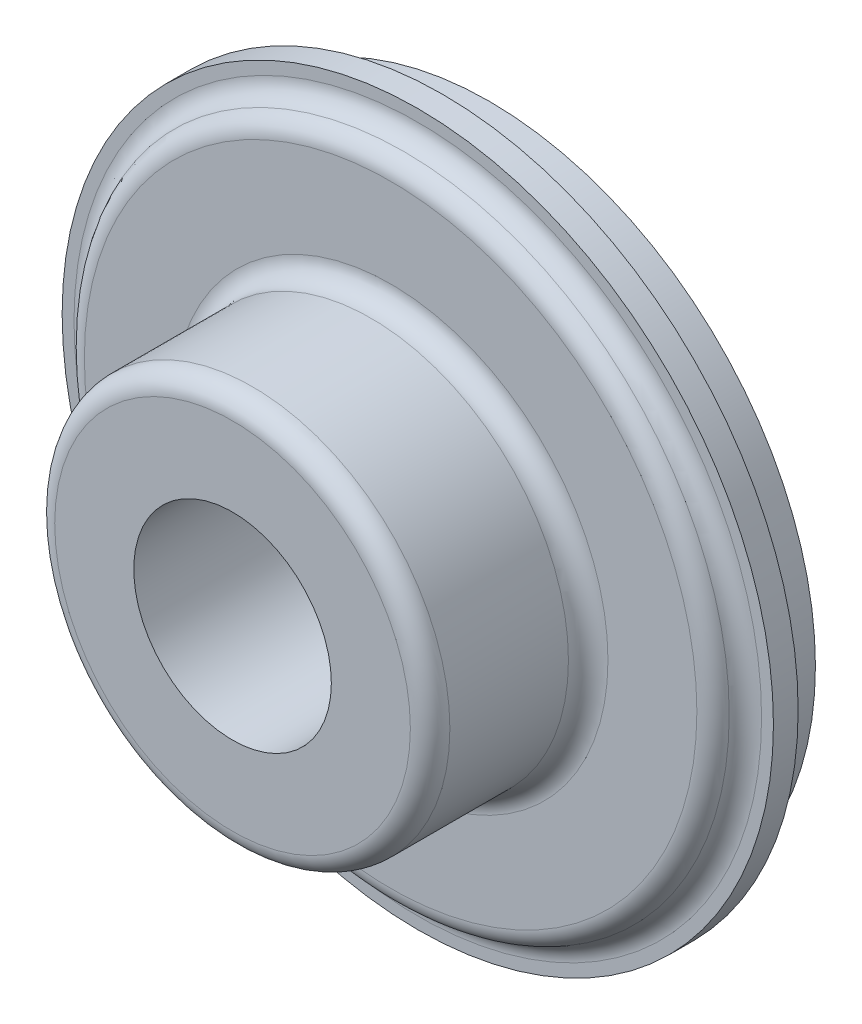
from build123d import *


with BuildPart() as part:
    # Sketch1 → Revolve1 (revolve)
    with BuildSketch(Plane(origin=(0, 0, 0), x_dir=(1, 0, 0), z_dir=(0, 1, 0))):
        with BuildLine():
            Line((22, -227), (31, -227))
            ThreePointArc((31, -227), (32.17260394, -226.620185175), (32.899835519, -225.625))
            ThreePointArc((32.899835519, -225.625), (33.627067098, -224.629814825), (34.799671038, -224.25))
            Line((34.799671038, -224.25), (36, -224.25))
            Line((36, -224.25), (36, -221.75))
            Line((36, -221.75), (33, -221.75))
            Line((33, -221.75), (33, -217))
            Line((33, -217), (27, -217))
            Line((27, -217), (27, -223))
            Line((27, -223), (21.819851171, -223))
            Line((21.819851171, -223), (20, -218))
            Line((20, -218), (20, -213))
            Line((20, -213), (18.659118994, -209.315959713))
            ThreePointArc((18.659118994, -209.315959713), (17.926886625, -208.361695911), (16.779733752, -208))
            Line((16.779733752, -208), (12, -208))
            ThreePointArc((12, -208), (10.585786438, -208.585786438), (10, -210))
            Line((10, -210), (10, -243))
            Line((10, -243), (18, -243))
            ThreePointArc((18, -243), (19.414213562, -242.414213562), (20, -241))
            Line((20, -241), (20, -229))
            ThreePointArc((20, -229), (20.585786438, -227.585786438), (22, -227))
        make_face()
    revolve(axis=Axis((0, 0, 208), (0, 0, 1)))


solid = part.part
